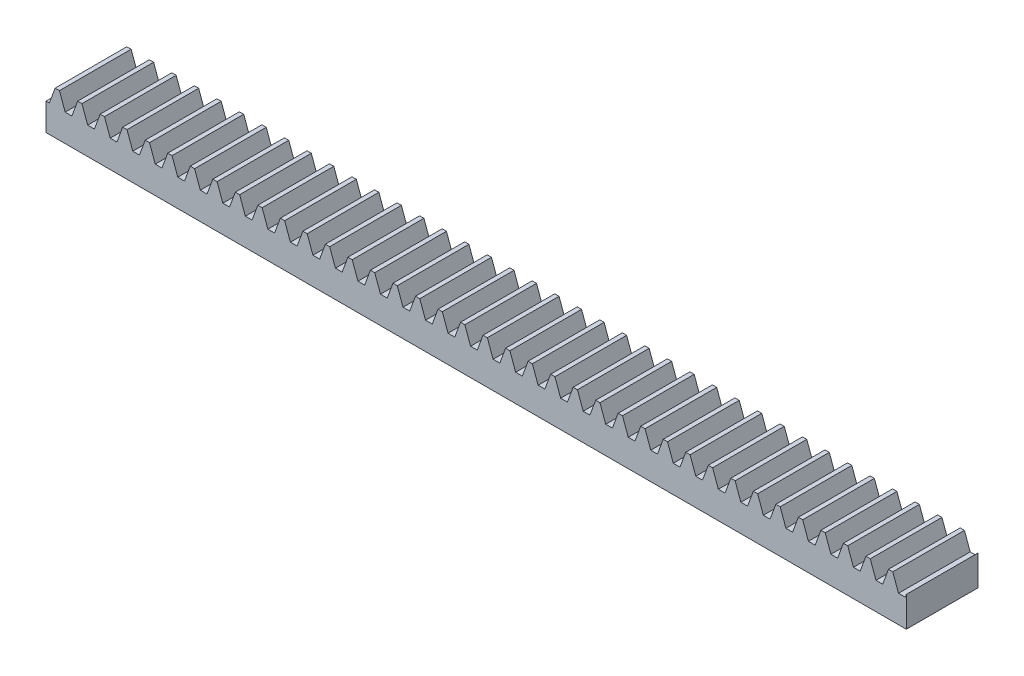
from build123d import *

# Parameters (mm, degrees)
BLANKSKE_W        = 152.4
BLANKSKE_H        = 7.62
BLANK_DEPTH       = 12.7
TOOTHCUTSIM_DEPTH = 154.117975431
TEETHCUTS_COUNT   = 39
TEETHCUTS_PITCH   = 3.989822666


with BuildPart() as part:
    # BlankSke → Blank (new body)
    with BuildSketch(Plane.XY):
        with Locations((76.2, 3.81)):
            Rectangle(BLANKSKE_W, BLANKSKE_H)
    extrude(amount=-BLANK_DEPTH)

    # TooCutSkeSim → ToothCutSim (cut, through all)
    with BuildSketch(Plane.XY):
        Polygon((0.595165029, 4.826), (-0.595165029, 4.826), (-1.621342708, 7.6454), (1.621342708, 7.6454), align=None)
    toothcutsim = extrude(amount=-TOOTHCUTSIM_DEPTH, mode=Mode.SUBTRACT)

    # TeethCuts: ToothCutSim ×39
    with Locations(*[(i * TEETHCUTS_PITCH, 0, 0) for i in range(1, TEETHCUTS_COUNT)]):
        add(toothcutsim, mode=Mode.SUBTRACT)


solid = part.part
